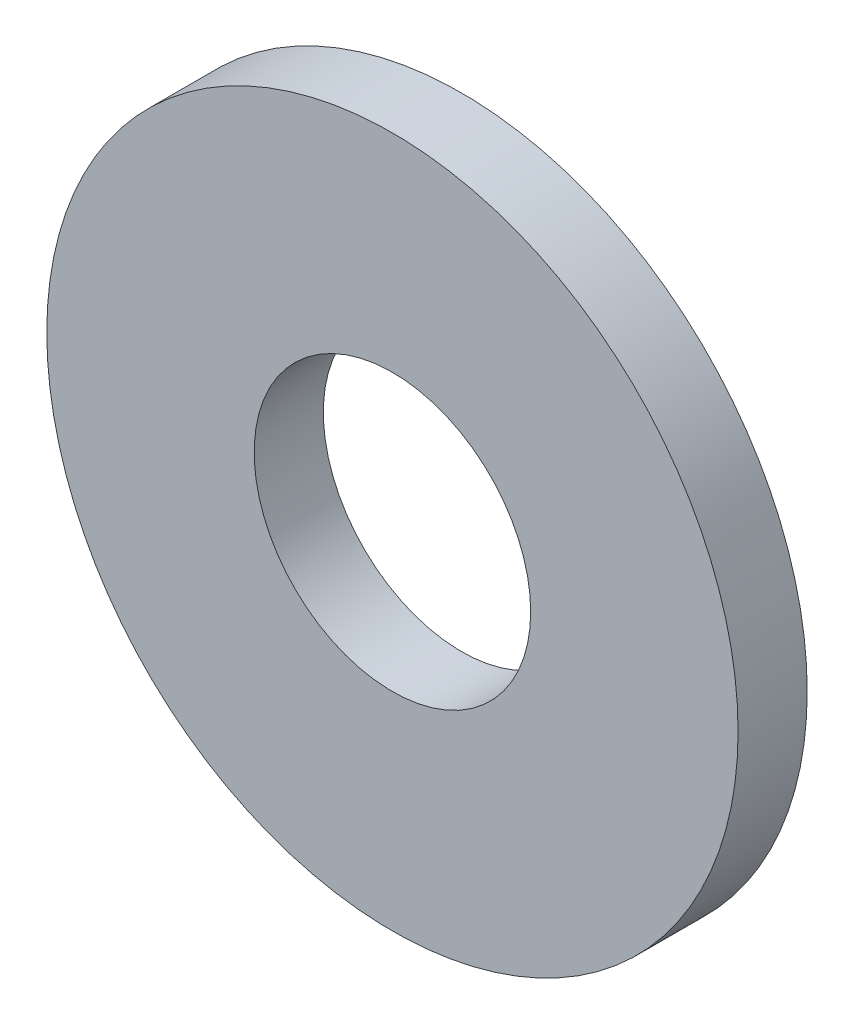
from build123d import *

# Parameters (mm, degrees)
SKETCH1_R           = 15.875
BOSS_EXTRUDE1_DEPTH = 3.175
SKETCH2_R           = 6.35
CUT_EXTRUDE1_DEPTH  = 3.175


with BuildPart() as part:
    # Sketch1 → Boss-Extrude1 (new body)
    with BuildSketch(Plane.XY):
        Circle(SKETCH1_R)
    extrude(amount=BOSS_EXTRUDE1_DEPTH)

    # Sketch2 → Cut-Extrude1 (cut)
    with BuildSketch(Plane.XY):
        Circle(SKETCH2_R)
    extrude(amount=CUT_EXTRUDE1_DEPTH, mode=Mode.SUBTRACT)


solid = part.part
